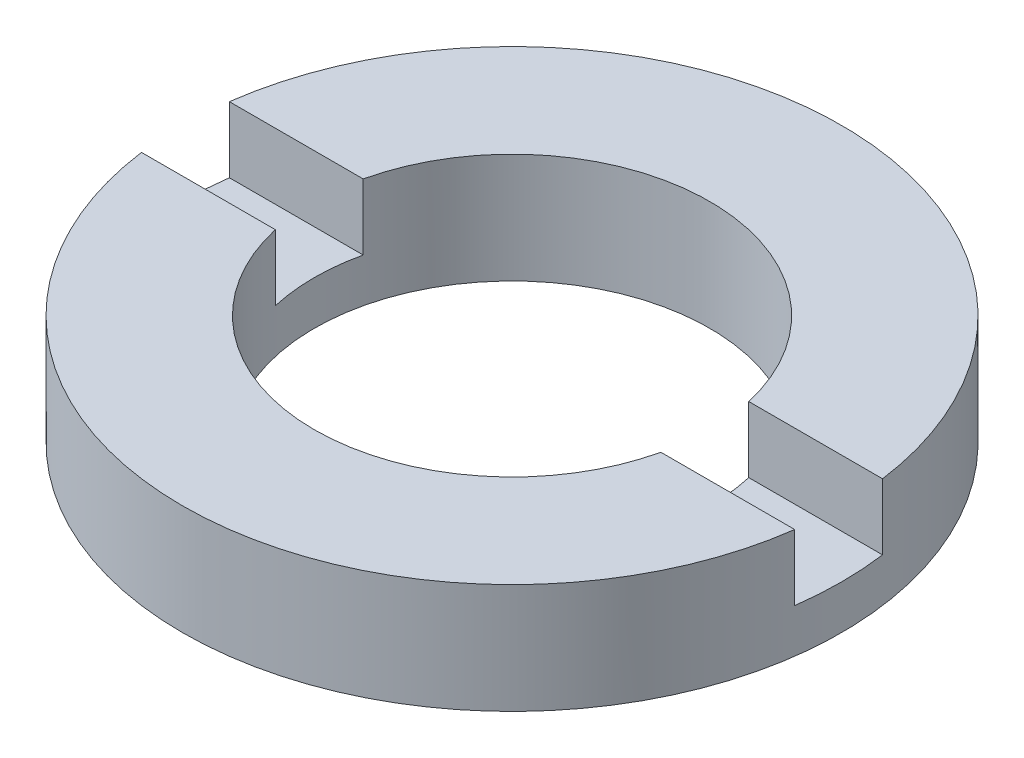
from build123d import *

# Parameters (mm, degrees)
SKETCH_1_W          = 3
SKETCH_1_H          = 2.5
SKETCH_2_W          = 53.705080546
SKETCH_2_H          = 2
CUT_EXTRUDE_1_DEPTH = 1.5


with BuildPart() as part:
    # 草图1 → 旋转1 (revolve)
    with BuildSketch(Plane.XY, mode=Mode.PRIVATE) as revolve_1_sk:
        with Locations((6, -3.214249787)):
            Rectangle(SKETCH_1_W, SKETCH_1_H)
    revolve(revolve_1_sk.sketch.rotate(Axis((0, 56.260842627, 0), (0, -1, 0)), 90), axis=Axis((0, 56.260842627, 0), (0, -1, 0)))  # turned: the seam where the file's is

    # 草图2 → 切除-拉伸1 (cut)
    with BuildSketch(Plane(origin=(0, -1.964249787, 0), x_dir=(1, 0, 0), z_dir=(0, 1, 0))):
        Rectangle(SKETCH_2_W, SKETCH_2_H)
    extrude(amount=-CUT_EXTRUDE_1_DEPTH, mode=Mode.SUBTRACT)


solid = part.part
